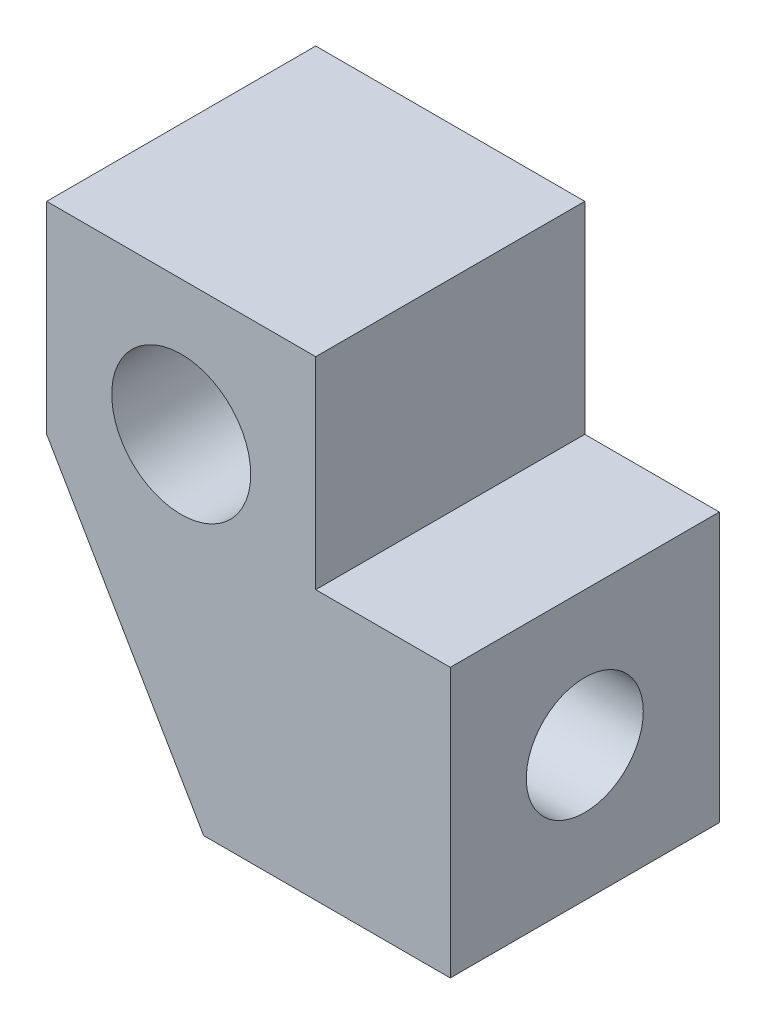
from build123d import *

# Parameters (mm, degrees)
SKETCH1_R           = 1.55
BOSS_EXTRUDE1_DEPTH = 6
SKETCH3_R           = 1.305
CUT_EXTRUDE3_DEPTH  = 10


with BuildPart() as part:
    # Sketch1 → Boss-Extrude1 (new body)
    with BuildSketch(Plane.XY):
        Polygon((48, -38), (45, -38), (45, -33.5), (39, -33.5), (39, -38), (42.5, -44), (48, -44), align=None)
        with Locations((42, -36.5)):
            Circle(SKETCH1_R, mode=Mode.SUBTRACT)
    extrude(amount=BOSS_EXTRUDE1_DEPTH)

    # Sketch3 → Cut-Extrude3 (cut, through all)
    with BuildSketch(Plane(origin=(48, 0, 0), x_dir=(0, 0, -1), z_dir=(1, 0, 0))):
        with Locations((-3, -41)):
            Circle(SKETCH3_R)
    extrude(amount=-CUT_EXTRUDE3_DEPTH, mode=Mode.SUBTRACT)


solid = part.part
